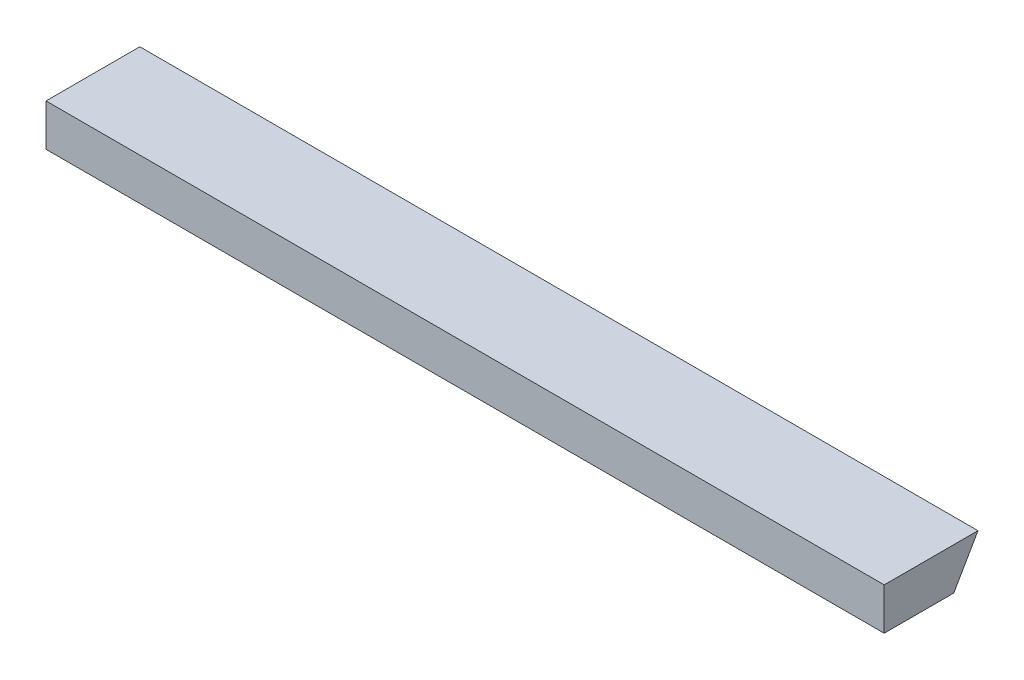
from build123d import *

# Parameters (mm, degrees)
SKETCH1_W               = 60.224174311
SKETCH1_H               = 12
BOSS_EXTRUDE1_DEPTH     = 240
CUT_EXTRUDE1_DEPTH      = 1
CUT_EXTRUDE1_DEPTH_BACK = 241


with BuildPart() as part:
    # Sketch1 → Boss-Extrude1 (new body)
    with BuildSketch(Plane(origin=(0, 0, 0), x_dir=(0, 0, -1), z_dir=(1, 0, 0))):
        with Locations((30.112087156, -6)):
            Rectangle(SKETCH1_W, SKETCH1_H)
    extrude(amount=-BOSS_EXTRUDE1_DEPTH)

    # Sketch2 → Cut-Extrude1 (cut, two sides)
    with BuildSketch(Plane(origin=(0, -88.996323208, -210.140507253), x_dir=(0, 0, -1), z_dir=(1, 0, 0))) as cut_extrude1_sk:
        Polygon((-381.473607845, -254.281529063), (-215.412171162, 33.34531645), (-115.125850584, 207.046318995), (50.935586099, 494.673164508), (626.189277125, 162.550291142), (193.780083181, -586.404402429), align=None)
    extrude(amount=CUT_EXTRUDE1_DEPTH, mode=Mode.SUBTRACT)
    extrude(cut_extrude1_sk.sketch, amount=-CUT_EXTRUDE1_DEPTH_BACK, mode=Mode.SUBTRACT)


solid = part.part
